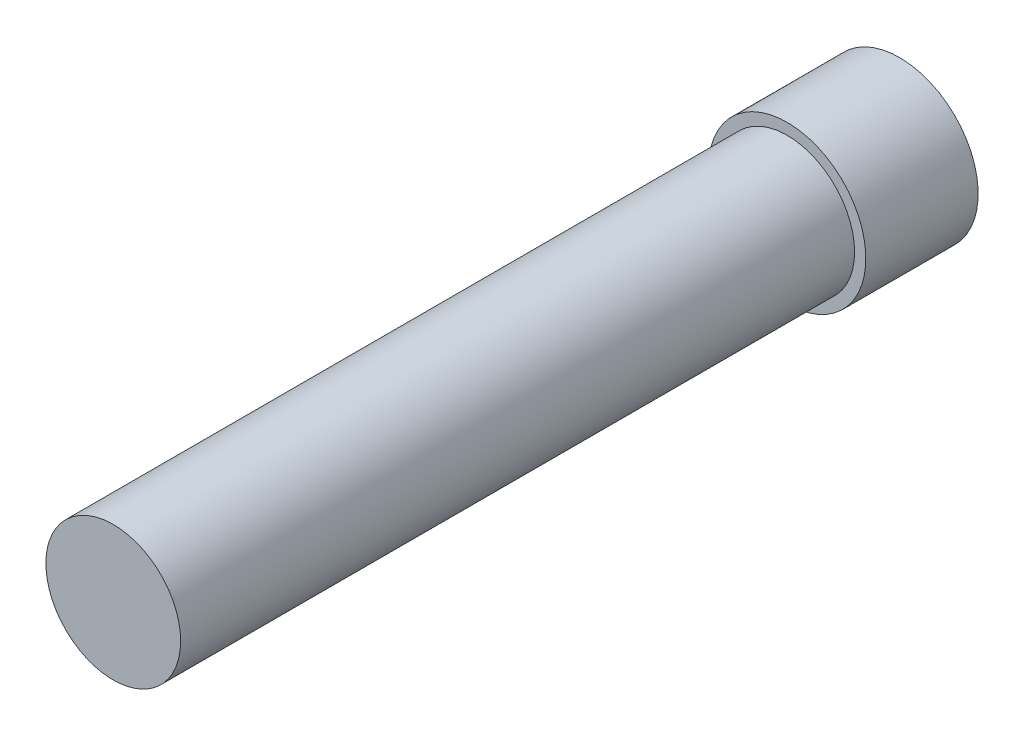
from build123d import *

# Parameters (mm, degrees)
SKETCH1_R           = 3
BOSS_EXTRUDE1_DEPTH = 30
SKETCH2_R           = 3.5
BOSS_EXTRUDE2_DEPTH = 5


with BuildPart() as part:
    # Sketch1 → Boss-Extrude1 (new body)
    with BuildSketch(Plane.XY):
        Circle(SKETCH1_R)
    extrude(amount=BOSS_EXTRUDE1_DEPTH)

    # Sketch2 → Boss-Extrude2 (add)
    with BuildSketch(Plane(origin=(0, 0, 0), x_dir=(-1, 0, 0), z_dir=(0, 0, -1))):
        Circle(SKETCH2_R)
    extrude(amount=BOSS_EXTRUDE2_DEPTH)


solid = part.part
